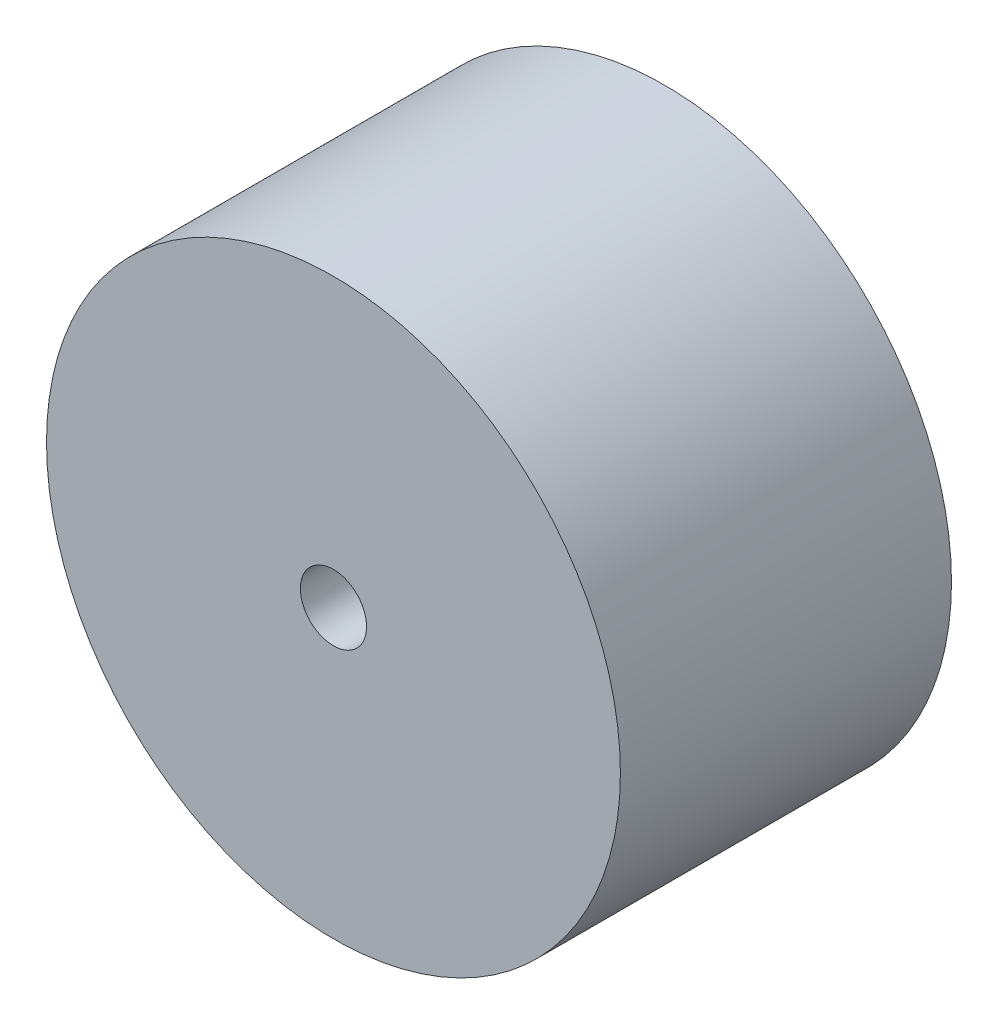
from build123d import *

# Parameters (mm, degrees)
SKETCH1_R           = 26
SKETCH1_R_2         = 22.5
SKETCH1_R_3         = 3
BOSS_EXTRUDE1_DEPTH = 30


with BuildPart() as part:
    # Sketch1 → Boss-Extrude1 (new body)
    with BuildSketch(Plane.XY):
        Circle(SKETCH1_R)
        Circle(SKETCH1_R_2, mode=Mode.SUBTRACT)
        Circle(SKETCH1_R_2)
        Circle(SKETCH1_R_3, mode=Mode.SUBTRACT)
    extrude(amount=BOSS_EXTRUDE1_DEPTH)


solid = part.part
